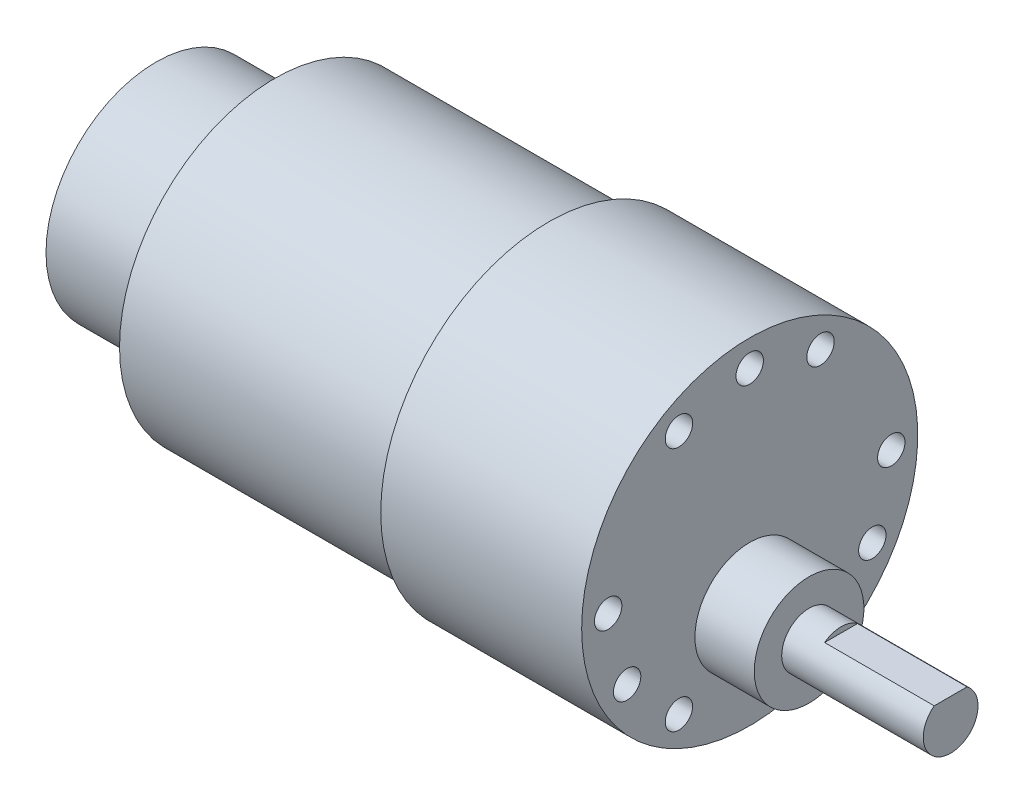
from build123d import *

# Parameters (mm, degrees)
ENL_V_MAT_EXTRU_1_DEPTH      = 10
ENL_V_MAT_EXTRU_1_DEPTH_BACK = 10
ESQUISSE4_W                  = 18.656759262
ESQUISSE4_H                  = 11.470185
ESQUISSE5_R                  = 12.05
ESQUISSE5_R_2                = 11.9
BOSS_EXTRU_1_DEPTH           = 13
ESQUISSE6_R                  = 1.5
ENL_V_MAT_EXTRU_2_DEPTH      = 5
R_P_TITION_CIRCULAIRE1_COUNT = 3


with BuildPart() as part:
    # Esquisse1 → Révolution1 (revolve)
    with BuildSketch(Plane.XY):
        Polygon((-30, 0), (-30, 17), (0, 17), (0, 18.4), (22, 18.4), (22, 0), align=None)
    revolve(axis=Axis((-59.117838542, 0, 0), (1, 0, 0)))

    # Esquisse3 → Révolution2 (revolve)
    with BuildSketch(Plane.XY):
        Polygon((22, -1), (28.5, -1), (28.5, -4), (44, -4), (44, -7), (22, -7), align=None)
    revolve(axis=Axis((8.410725031, -7, 0), (1, 0, 0)))

    # Esquisse4 → Enlèv. mat.-Extru.1 (cut, two sides: drawn at the far end of the back side and taken through both)
    with BuildSketch(Plane.XY.offset(-ENL_V_MAT_EXTRU_1_DEPTH_BACK)):
        with Locations((41.328379631, 1.1350925)):
            Rectangle(ESQUISSE4_W, ESQUISSE4_H)
    extrude(amount=ENL_V_MAT_EXTRU_1_DEPTH + ENL_V_MAT_EXTRU_1_DEPTH_BACK, mode=Mode.SUBTRACT)

    # Esquisse5 → Boss.-Extru.1 (add)
    with BuildSketch(Plane.ZY.offset(30)):
        Circle(ESQUISSE5_R)
        Circle(ESQUISSE5_R_2, mode=Mode.SUBTRACT)
    extrude(amount=BOSS_EXTRU_1_DEPTH)

    # Esquisse6 → Enlèv. mat.-Extru.2 (cut)
    with BuildSketch(Plane(origin=(22, 0, 0), x_dir=(0, 0, -1), z_dir=(1, 0, 0))):
        with Locations((0, 15.5)):
            Circle(ESQUISSE6_R)
        with Locations((7.75, 13.423393759)):
            Circle(ESQUISSE6_R)
        with Locations((-7.75, 13.423393759)):
            Circle(ESQUISSE6_R)
    enl_v_mat_extru_2 = extrude(amount=-ENL_V_MAT_EXTRU_2_DEPTH, mode=Mode.SUBTRACT)

    # Répétition circulaire1: Enlèv. mat.-Extru.2 ×3 about axis
    r_p_tition_circulaire1_axis = Axis((22, 0, 0), (-1, 0, 0))
    for i in range(1, R_P_TITION_CIRCULAIRE1_COUNT):
        add(enl_v_mat_extru_2.rotate(r_p_tition_circulaire1_axis, i * 360 / R_P_TITION_CIRCULAIRE1_COUNT), mode=Mode.SUBTRACT)


solid = part.part
